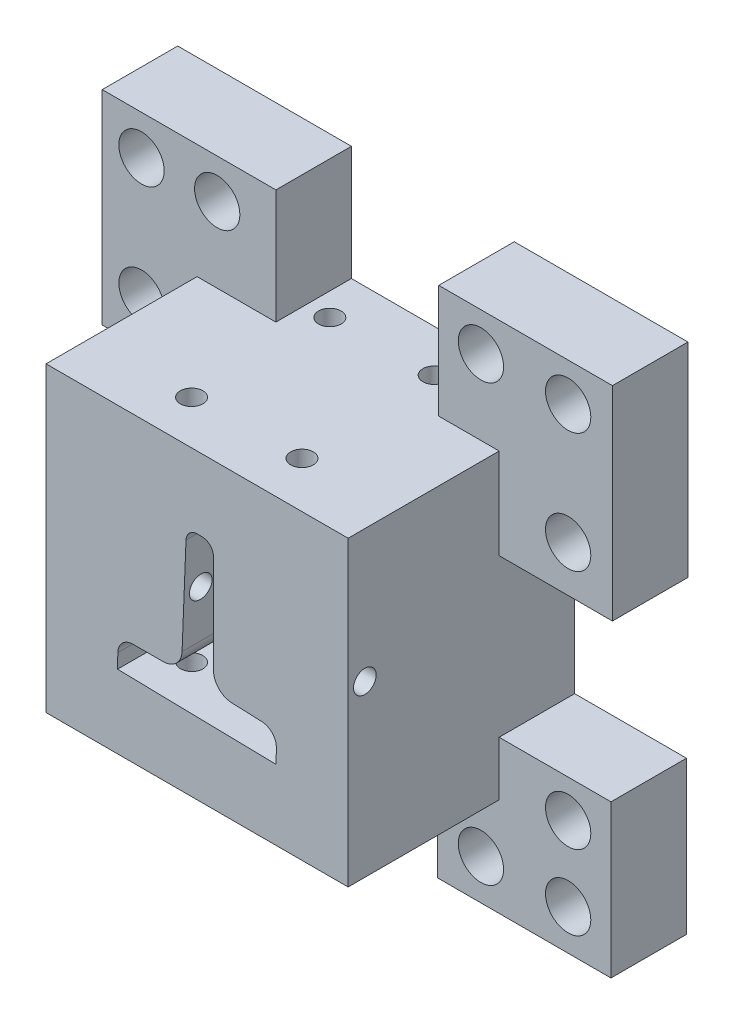
from build123d import *

# Parameters (mm, degrees)
ESQUISSE1_W             = 40
ESQUISSE1_H             = 40
BOSS_EXTRU_1_DEPTH      = 30
ENL_V_MAT_EXTRU_1_DEPTH = 30
ESQUISSE4_R             = 1.5
ENL_V_MAT_EXTRU_2_DEPTH = 41
ESQUISSE5_R             = 1.5
ENL_V_MAT_EXTRU_3_DEPTH = 41
ESQUISSE6_W             = 23
ESQUISSE6_H             = 27
ESQUISSE6_H_2           = 20.20636544
ESQUISSE6_H_3           = 20.206365439
BOSS_EXTRU_2_DEPTH      = 10
ESQUISSE7_R             = 3
ENL_V_MAT_EXTRU_4_DEPTH = 11.0000001


with BuildPart() as part:
    # Esquisse1 → Boss.-Extru.1 (new body)
    with BuildSketch(Plane.XY):
        with Locations((0, 559.576541314)):
            Rectangle(ESQUISSE1_W, ESQUISSE1_H)
        with BuildLine():
            Line((-10.025728158, 549.777097393), (9.970271386, 549.3770946))
            Line((9.970271386, 549.3770946), (9.998865294, 550.806494043))
            ThreePointArc((9.998865294, 550.806494043), (9.591165544, 551.864859717), (8.559153746, 552.335294236))
            Line((8.559153746, 552.335294236), (4.551996141, 552.495677906))
            ThreePointArc((4.551996141, 552.495677906), (2.508650242, 553.414808545), (1.671972976, 555.493277873))
            Line((1.671972976, 555.493277873), (1.671972976, 568.566900265))
            ThreePointArc((1.671972976, 568.566900265), (1.386115868, 569.266900215), (0.691973116, 569.566700242))
            Line((0.691973116, 569.566700242), (0.052575697, 569.579490838))
            ThreePointArc((0.052575697, 569.579490838), (-0.653001419, 569.307691005), (-0.966624431, 568.619683139))
            Line((-0.966624431, 568.619683139), (-1.489468376, 555.556519791))
            ThreePointArc((-1.489468376, 555.556519791), (-2.408599014, 553.513173892), (-4.487068342, 552.676496626))
            Line((-4.487068342, 552.676496626), (-8.497434284, 552.676496626))
            ThreePointArc((-8.497434284, 552.676496626), (-9.54743421, 552.247710964), (-9.99713425, 551.206496835))
            Line((-9.99713425, 551.206496835), (-10.025728158, 549.777097393))
        make_face(mode=Mode.SUBTRACT)
    extrude(amount=BOSS_EXTRU_1_DEPTH)

    # Esquisse3 → Enlèv. mat.-Extru.1 (cut)
    with BuildSketch(Plane.XY.offset(30)):
        with BuildLine():
            Line((0.701973186, 570.066600231), (0.062575767, 570.079390827))
            ThreePointArc((0.062575767, 570.079390827), (-0.995789907, 569.671691077), (-1.466224425, 568.639679279))
            Line((-1.466224425, 568.639679279), (-1.98906837, 555.57651593))
            ThreePointArc((-1.98906837, 555.57651593), (-2.755010569, 553.873727681), (-4.487068342, 553.176496626))
            Line((-4.487068342, 553.176496626), (-8.497434284, 553.176496626))
            ThreePointArc((-8.497434284, 553.176496626), (-9.897434185, 552.604782409), (-10.497034239, 551.216496905))
            Line((-10.497034239, 551.216496905), (-10.535628216, 549.287197474))
            Line((-10.535628216, 549.287197474), (10.460171305, 548.867194542))
            Line((10.460171305, 548.867194542), (10.498765283, 550.796493973))
            ThreePointArc((10.498765283, 550.796493973), (9.955165615, 552.207648206), (8.579149885, 552.83489423))
            Line((8.579149885, 552.83489423), (4.57199228, 552.995277901))
            ThreePointArc((4.57199228, 552.995277901), (2.869204031, 553.761220099), (2.171972976, 555.493277873))
            Line((2.171972976, 555.493277873), (2.171972976, 568.566900265))
            ThreePointArc((2.171972976, 568.566900265), (1.743187314, 569.61690019), (0.701973186, 570.066600231))
        make_face()
    extrude(amount=-ENL_V_MAT_EXTRU_1_DEPTH, mode=Mode.SUBTRACT)

    # Esquisse4 → Enlèv. mat.-Extru.2 (cut, through all)
    with BuildSketch(Plane.XZ.offset(-539.576541314)):
        with Locations(Location((-6.523433168, 24.203853726, 0), (0, 0, 270))):  # turned: the seam where the file's is
            Circle(ESQUISSE4_R)
        with Locations(Location((-6.523433168, 5.901559872, 0), (0, 0, 270))):  # turned: the seam where the file's is
            Circle(ESQUISSE4_R)
        with Locations((7.005369476, 5.612158233)):
            Circle(ESQUISSE4_R)
        with Locations((7.788039062, 23.897709596)):
            Circle(ESQUISSE4_R)
    extrude(amount=-ENL_V_MAT_EXTRU_2_DEPTH, mode=Mode.SUBTRACT)

    # Esquisse5 → Enlèv. mat.-Extru.3 (cut, through all)
    with BuildSketch(Plane.ZY.offset(20)):
        with Locations(Location((27.786828978, 562.049365696, 0), (0, 0, 270))):  # turned: the seam where the file's is
            Circle(ESQUISSE5_R)
        with Locations(Location((2.00094519, 562.049365696, 0), (0, 0, 270))):  # turned: the seam where the file's is
            Circle(ESQUISSE5_R)
    extrude(amount=-ENL_V_MAT_EXTRU_3_DEPTH, mode=Mode.SUBTRACT)

    # Esquisse6 → Boss.-Extru.2 (add)
    with BuildSketch(Plane(origin=(0, 0, 0), x_dir=(-1, 0, 0), z_dir=(0, 0, -1))):
        with Locations((-23.5, 581.076541314)):
            Rectangle(ESQUISSE6_W, ESQUISSE6_H)
        with Locations((22.166061681, 537.286666725)):
            Rectangle(ESQUISSE6_W, ESQUISSE6_H_2)
        with Locations((21.063566891, 581.241581079)):
            Rectangle(ESQUISSE6_W, ESQUISSE6_H)
        with Locations((-23.306010365, 536.648365215)):
            Rectangle(ESQUISSE6_W, ESQUISSE6_H_3)
    extrude(amount=-BOSS_EXTRU_2_DEPTH)

    # Esquisse7 → Enlèv. mat.-Extru.4 (cut, through all)
    with BuildSketch(Plane.XY.offset(10)):
        with Locations((-27.359707791, 589.516341352)):
            Circle(ESQUISSE7_R)
        with Locations((-27.359707791, 573.664786381)):
            Circle(ESQUISSE7_R)
        with Locations((-27.359707791, 541.773153337)):
            Circle(ESQUISSE7_R)
        with Locations((-27.359707791, 531.883070045)):
            Circle(ESQUISSE7_R)
        with Locations((-17.338422342, 531.883070045)):
            Circle(ESQUISSE7_R)
        with Locations((-17.338422342, 589.516341352)):
            Circle(ESQUISSE7_R)
        with Locations((17.587577233, 589.516341352)):
            Circle(ESQUISSE7_R)
        with Locations((29.13602426, 589.516341352)):
            Circle(ESQUISSE7_R)
        with Locations((29.13602426, 573.664786381)):
            Circle(ESQUISSE7_R)
        with Locations((29.13602426, 541.773153337)):
            Circle(ESQUISSE7_R)
        with Locations((29.13602426, 531.883070045)):
            Circle(ESQUISSE7_R)
        with Locations((17.587577233, 531.883070045)):
            Circle(ESQUISSE7_R)
    extrude(amount=-ENL_V_MAT_EXTRU_4_DEPTH, mode=Mode.SUBTRACT)


solid = part.part
